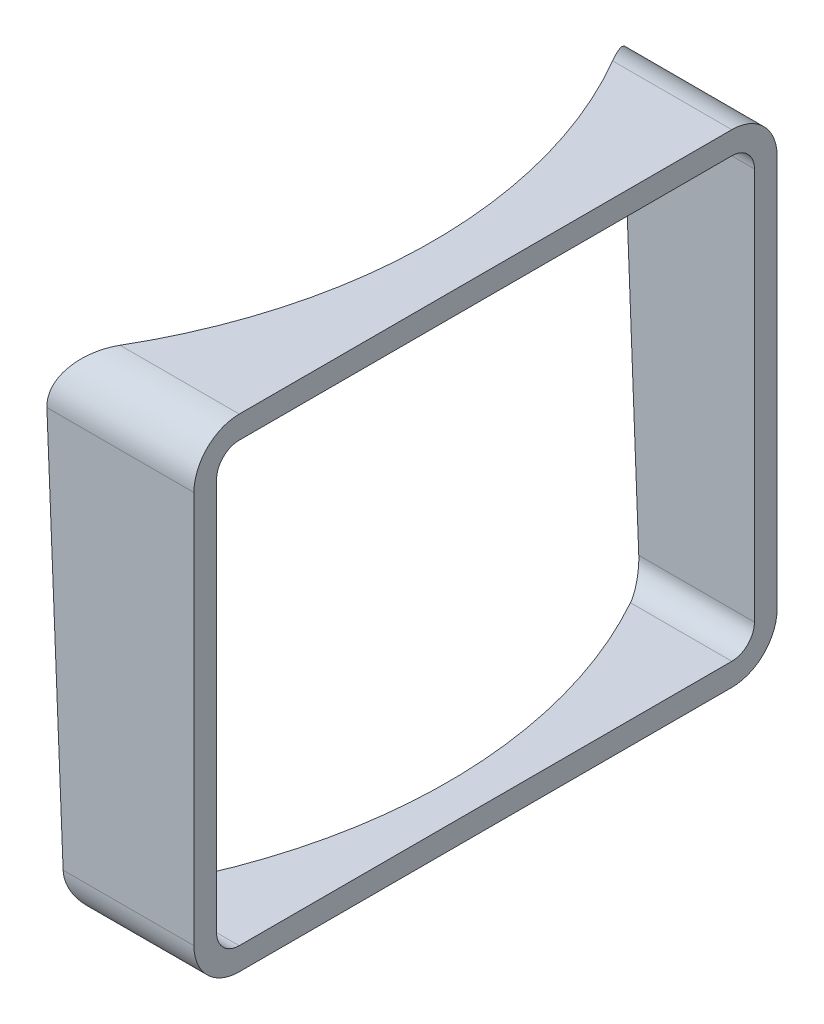
from build123d import *

# Parameters (mm, degrees)
BOSS_EXTRUDE1_DEPTH = 106.64
FILLET1_R           = 10
SHELL1_T            = -5


with BuildPart() as part:
    # Sketch1 → Boss-Extrude1 (new body)
    with BuildSketch(Plane(origin=(0, 0, 0), x_dir=(1, 0, 0), z_dir=(0, 1, 0))):
        Polygon((1.515e-14, 64.36916415), (-58.4134595853381, 64.36916415000002), (-58.4134595853381, -64.36916415000002), (1.515e-14, -64.36916415), align=None)
    extrude(amount=-BOSS_EXTRUDE1_DEPTH)

    # Sketch2 → Cut-Revolve1 (revolve, cut)
    with BuildSketch(Plane.XY):
        Polygon((-11.66115202408946, 0), (-8.083701414949179, -106.64), (-119.91640215317999, -106.64), (-119.91640215318, 0), align=None)
    revolve(axis=Axis((-119.91640215318, 0, 0), (1.3e-16, -1, 0)), mode=Mode.SUBTRACT)

    # Fillet1
    fillet1_edges = [part.edges().sort_by_distance(p)[0] for p in [
        (-14.233033878872398, -106.64, 64.36916415),
        (-14.233033878872396, -106.64, -64.36916415),
        (-16.438636834910113, 0, 64.36916415),
        (-16.43863683491015, 0, -64.36916415),
    ]]
    fillet(fillet1_edges, radius=FILLET1_R)

    # Shell1
    shell1_openings = [part.faces().sort_by_distance(p)[0] for p in [
        (-9.87242672, -53.32, 0),
        (0, -53.32, 0),
    ]]
    offset(amount=SHELL1_T, openings=shell1_openings)


solid = part.part
